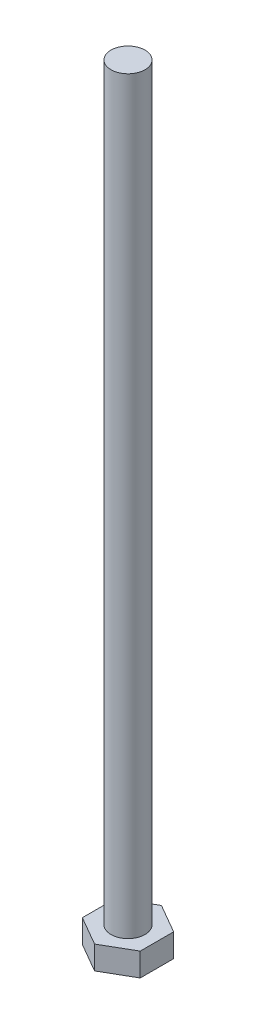
from build123d import *

# Parameters (mm, degrees)
EXTRUDE_1_DEPTH = 8
SKETCH_2_R      = 5
EXTRUDE_2_DEPTH = 220
CHAMFER_1_SIZE  = 2
CHAMFER_1_SIZE2 = 1.154700538


with BuildPart() as part:
    # Эскиз1 → Бобышка-Вытянуть1 (new body)
    with BuildSketch(Plane(origin=(0, 0, 0), x_dir=(1, 0, 0), z_dir=(0, 1, 0))):
        Polygon((8.5, -4.907477288), (8.5, 4.907477288), (0, 9.814954576), (-8.5, 4.907477288), (-8.5, -4.907477288), (0, -9.814954576), align=None)
    extrude(amount=EXTRUDE_1_DEPTH)

    # Эскиз2 → Бобышка-Вытянуть2 (add)
    with BuildSketch(Plane(origin=(0, 8, 0), x_dir=(1, 0, 0), z_dir=(0, 1, 0))):
        Circle(SKETCH_2_R)
    extrude(amount=EXTRUDE_2_DEPTH)

    # Фаска1
    chamfer_1_edges = [part.edges().sort_by_distance(p)[0] for p in [
        (-4.25, 0, 7.361215932),
        (-8.5, 0, 0),
        (-4.25, 0, -7.361215932),
        (4.25, 0, -7.361215932),
        (8.5, 0, 0),
        (4.25, 0, 7.361215932),
    ]]
    chamfer_1_side = [part.faces().sort_by_distance(p)[0] for p in [
        (0, 0, 0),
    ]]
    chamfer(chamfer_1_edges, length=CHAMFER_1_SIZE, length2=CHAMFER_1_SIZE2, reference=chamfer_1_side[0])


solid = part.part
